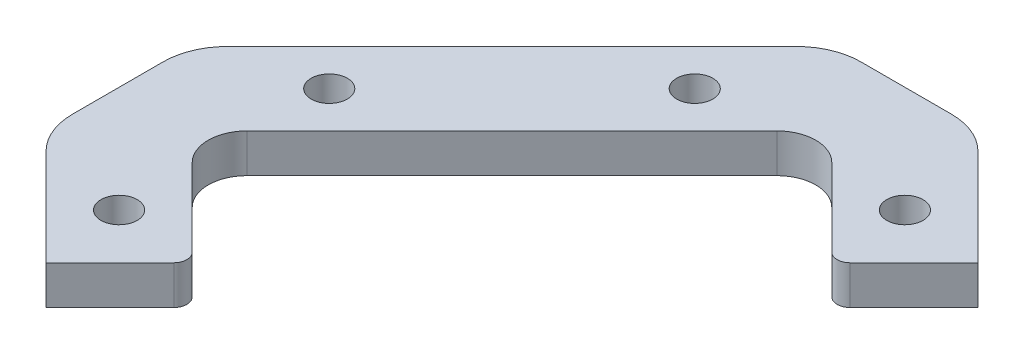
from build123d import *

# Parameters (mm, degrees)
SKETCH1_R           = 1.4
BOSS_EXTRUDE1_DEPTH = 3


with BuildPart() as part:
    # Sketch1 → Boss-Extrude1 (new body)
    with BuildSketch(Plane(origin=(0, 0, 0), x_dir=(1, 0, 0), z_dir=(0, 1, 0))):
        with BuildLine():
            Line((-6.037453791, -13.924683413), (-12.047861431, -7.914275773))
            ThreePointArc((-12.047861431, -7.914275773), (-12.926541087, -5.792955429), (-12.047861431, -3.671635086))
            Line((-12.047861431, -3.671635086), (8.458235223, 16.834461569))
            ThreePointArc((8.458235223, 16.834461569), (10.579555567, 17.713141225), (12.700875911, 16.834461569))
            Line((12.700875911, 16.834461569), (18.711283551, 10.824053929))
            ThreePointArc((18.711283551, 10.824053929), (19.418390332, 10.53116071), (20.125497113, 10.824053929))
            Line((20.125497113, 10.824053929), (25.075244581, 15.773801397))
            Line((25.075244581, 15.773801397), (17.606467502, 23.242578477))
            ThreePointArc((17.606467502, 23.242578477), (15.984350757, 24.326442233), (14.070933596, 24.707044571))
            Line((14.070933596, 24.707044571), (7.088177538, 24.707044571))
            ThreePointArc((7.088177538, 24.707044571), (5.174760376, 24.326442233), (3.552643632, 23.242578477))
            Line((3.552643632, 23.242578477), (-18.455978339, 1.233956505))
            ThreePointArc((-18.455978339, 1.233956505), (-19.539842096, -0.388160239), (-19.920444433, -2.301577401))
            Line((-19.920444433, -2.301577401), (-19.920444433, -9.284333458))
            ThreePointArc((-19.920444433, -9.284333458), (-19.539842096, -11.19775062), (-18.455978339, -12.819867364))
            Line((-18.455978339, -12.819867364), (-10.987201259, -20.288644444))
            Line((-10.987201259, -20.288644444), (-6.037453791, -15.338896975))
            ThreePointArc((-6.037453791, -15.338896975), (-5.744560572, -14.631790194), (-6.037453791, -13.924683413))
        make_face()
        with Locations((18.711283551, 16.480908178)):
            Circle(SKETCH1_R, mode=Mode.SUBTRACT)
        with Locations((2.447827583, 16.480908178)):
            Circle(SKETCH1_R, mode=Mode.SUBTRACT)
        with Locations((-11.69430804, 2.338772554)):
            Circle(SKETCH1_R, mode=Mode.SUBTRACT)
        with Locations((-11.69430804, -13.924683413)):
            Circle(SKETCH1_R, mode=Mode.SUBTRACT)
    extrude(amount=BOSS_EXTRUDE1_DEPTH)


solid = part.part
